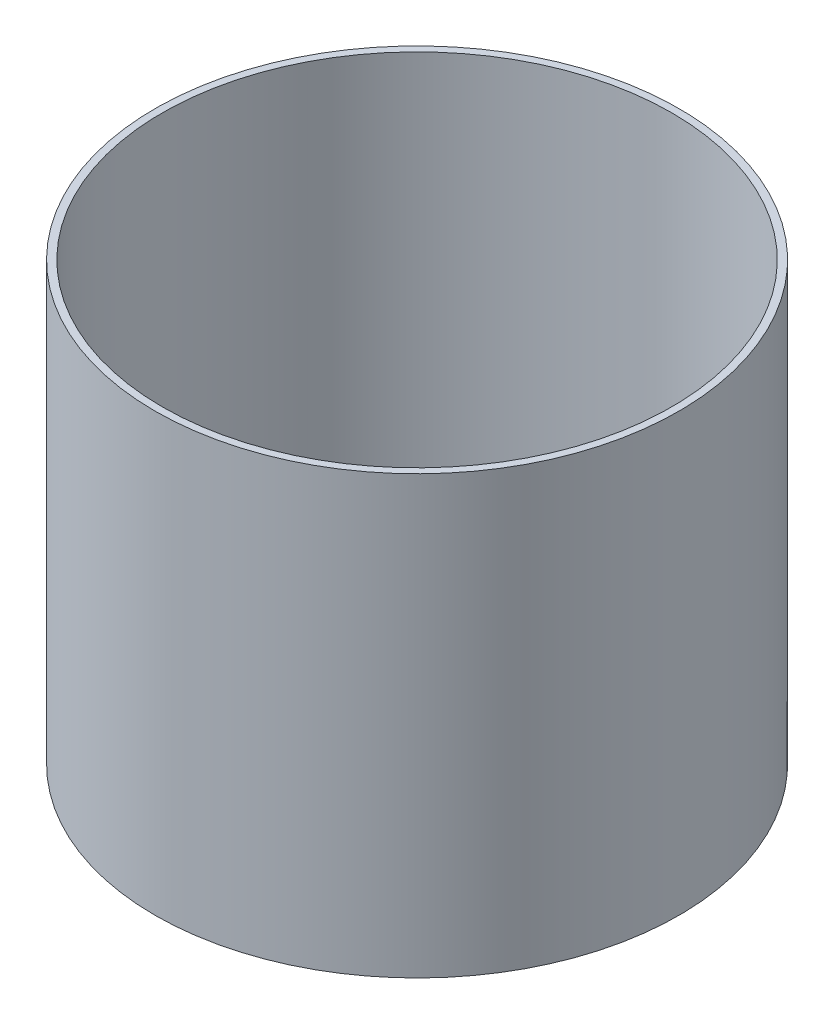
from build123d import *

# Parameters (mm, degrees)
SKETCH1_R           = 36
SKETCH1_R_2         = 35
BOSS_EXTRUDE1_DEPTH = 60


with BuildPart() as part:
    # Sketch1 → Boss-Extrude1 (new body)
    with BuildSketch(Plane(origin=(0, 0, 0), x_dir=(1, 0, 0), z_dir=(0, 1, 0))):
        Circle(SKETCH1_R)
        Circle(SKETCH1_R_2, mode=Mode.SUBTRACT)
    extrude(amount=BOSS_EXTRUDE1_DEPTH)


solid = part.part
